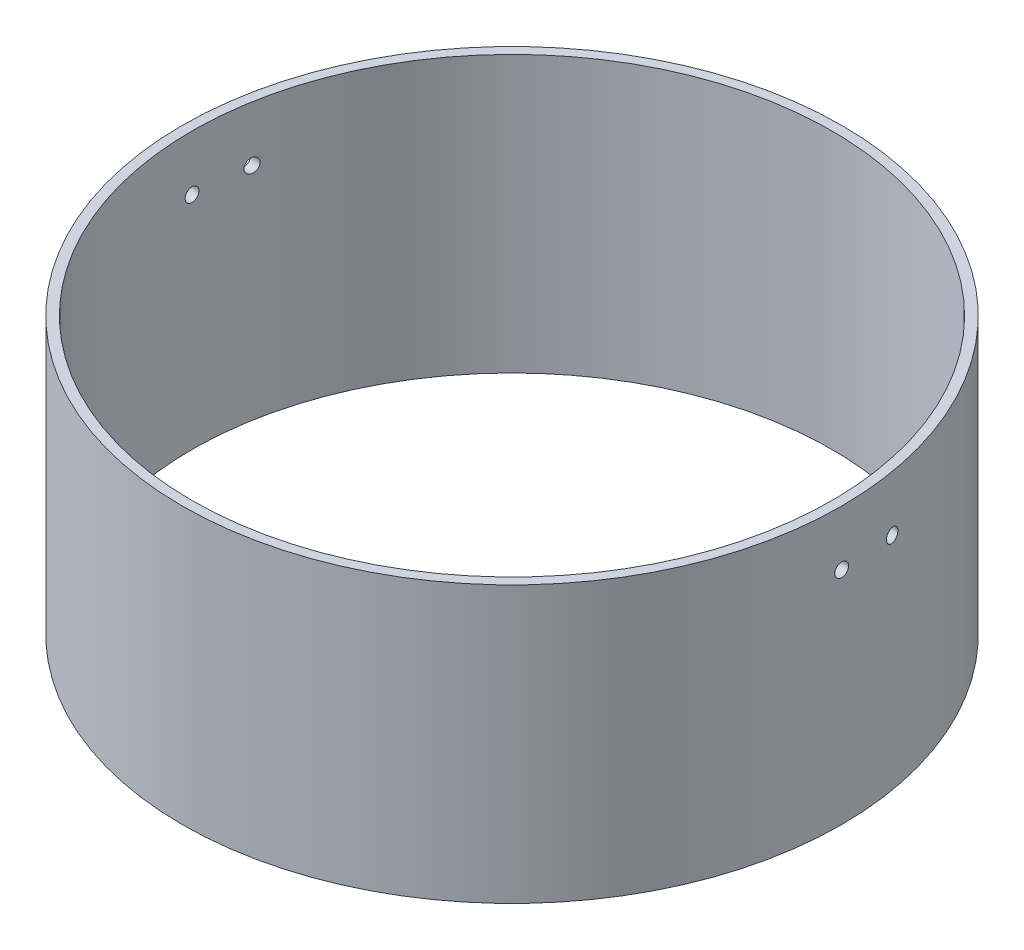
from build123d import *

# Parameters (mm, degrees)
SKETCH1_R               = 75.8825
BOSS_EXTRUDE1_DEPTH     = 63.5
SKETCH2_R               = 73.66
CUT_EXTRUDE1_DEPTH      = 101.6
SKETCH4_R               = 1.5875
CUT_EXTRUDE4_DEPTH      = 76.8825
CUT_EXTRUDE4_DEPTH_BACK = 76.8825


with BuildPart() as part:
    # Sketch1 → Boss-Extrude1 (new body)
    with BuildSketch(Plane(origin=(0, 0, 0), x_dir=(1, 0, 0), z_dir=(0, 1, 0))):
        Circle(SKETCH1_R)
    extrude(amount=BOSS_EXTRUDE1_DEPTH)

    # Sketch2 → Cut-Extrude1 (cut)
    with BuildSketch(Plane(origin=(0, 63.5, 0), x_dir=(1, 0, 0), z_dir=(0, 1, 0))):
        Circle(SKETCH2_R)
    extrude(amount=-CUT_EXTRUDE1_DEPTH, mode=Mode.SUBTRACT)

    # Sketch4 → Cut-Extrude4 (cut, two sides)
    with BuildSketch(Plane(origin=(0, 0, 0), x_dir=(0, 0, -1), z_dir=(1, 0, 0))) as cut_extrude4_sk:
        with Locations((0, 50.8)):
            Circle(SKETCH4_R)
        with Locations((12.7, 50.8)):
            Circle(SKETCH4_R)
    extrude(amount=CUT_EXTRUDE4_DEPTH, mode=Mode.SUBTRACT)
    extrude(cut_extrude4_sk.sketch, amount=-CUT_EXTRUDE4_DEPTH_BACK, mode=Mode.SUBTRACT)


solid = part.part
